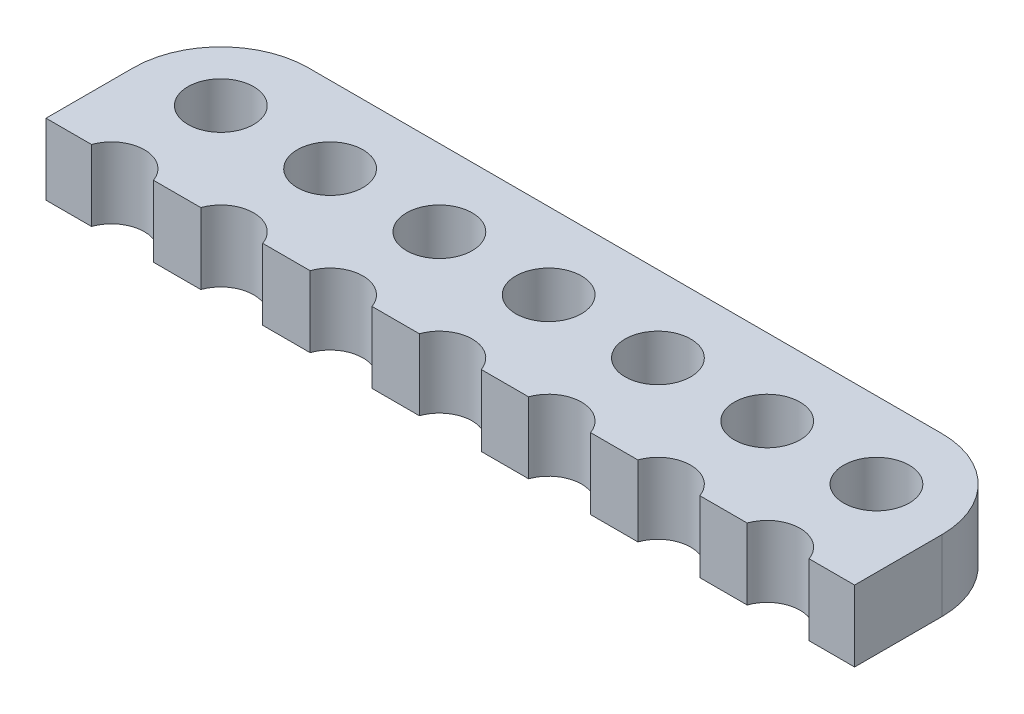
from build123d import *

# Parameters (mm, degrees)
SKETCH1_R           = 1.5025
BOSS_EXTRUDE1_DEPTH = 3.25


with BuildPart() as part:
    # Sketch1 → Boss-Extrude1 (new body)
    with BuildSketch(Plane(origin=(0, 0, 0), x_dir=(1, 0, 0), z_dir=(0, 1, 0))):
        with BuildLine():
            Line((-14.5, 4), (14.5, 4))
            ThreePointArc((14.5, 4), (17.328427125, 2.828427125), (18.5, 0))
            Line((18.5, 0), (18.5, -4))
            Line((18.5, -4), (16.416864937, -4))
            ThreePointArc((16.416864937, -4), (15, -2.9975), (13.583135063, -4))
            Line((13.583135063, -4), (11.416864937, -4))
            ThreePointArc((11.416864937, -4), (10, -2.9975), (8.583135063, -4))
            Line((8.583135063, -4), (6.416864937, -4))
            ThreePointArc((6.416864937, -4), (5, -2.9975), (3.583135063, -4))
            Line((3.583135063, -4), (1.416864937, -4))
            ThreePointArc((1.416864937, -4), (0, -2.9975), (-1.416864937, -4))
            Line((-1.416864937, -4), (-3.583135063, -4))
            ThreePointArc((-3.583135063, -4), (-5, -2.9975), (-6.416864937, -4))
            Line((-6.416864937, -4), (-8.583135063, -4))
            ThreePointArc((-8.583135063, -4), (-10, -2.9975), (-11.416864937, -4))
            Line((-11.416864937, -4), (-13.583135063, -4))
            ThreePointArc((-13.583135063, -4), (-15, -2.9975), (-16.416864937, -4))
            Line((-16.416864937, -4), (-18.5, -4))
            Line((-18.5, -4), (-18.5, 0))
            ThreePointArc((-18.5, 0), (-17.328427125, 2.828427125), (-14.5, 4))
        make_face()
        with Locations((-15, 0.5)):
            Circle(SKETCH1_R, mode=Mode.SUBTRACT)
        with Locations((-10, 0.5)):
            Circle(SKETCH1_R, mode=Mode.SUBTRACT)
        with Locations((-5, 0.5)):
            Circle(SKETCH1_R, mode=Mode.SUBTRACT)
        with Locations((0, 0.5)):
            Circle(SKETCH1_R, mode=Mode.SUBTRACT)
        with Locations((5, 0.5)):
            Circle(SKETCH1_R, mode=Mode.SUBTRACT)
        with Locations((10, 0.5)):
            Circle(SKETCH1_R, mode=Mode.SUBTRACT)
        with Locations((15, 0.5)):
            Circle(SKETCH1_R, mode=Mode.SUBTRACT)
    extrude(amount=BOSS_EXTRUDE1_DEPTH)


solid = part.part
